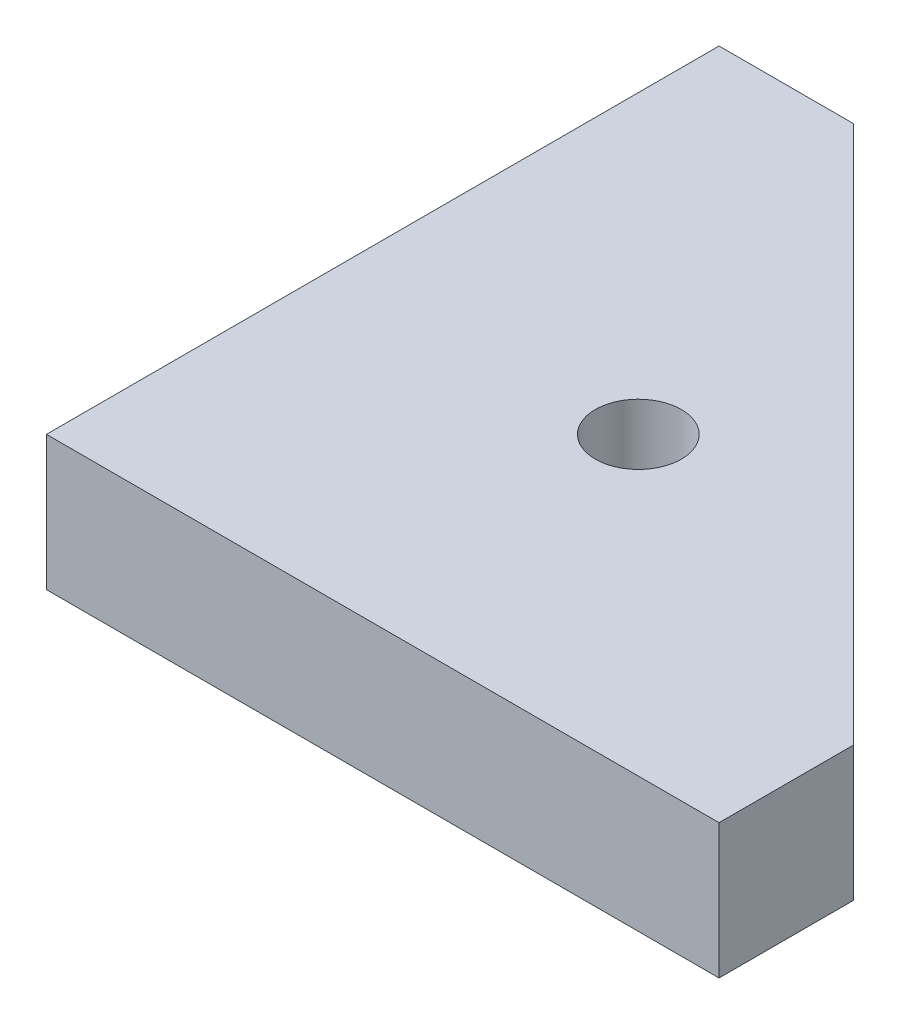
from build123d import *

# Parameters (mm, degrees)
SKETCH_1_R      = 1.6
EXTRUDE_1_DEPTH = 5


with BuildPart() as part:
    # ｽｹｯﾁ1 → ﾎﾞｽ - 押し出し1 (new body)
    with BuildSketch(Plane(origin=(0, 0, 0), x_dir=(1, 0, 0), z_dir=(0, 1, 0))):
        Polygon((25, 5), (5, 25), (0, 25), (0, 0), (25, 0), align=None)
        with Locations((11, 11)):
            Circle(SKETCH_1_R, mode=Mode.SUBTRACT)
    extrude(amount=EXTRUDE_1_DEPTH)


solid = part.part
